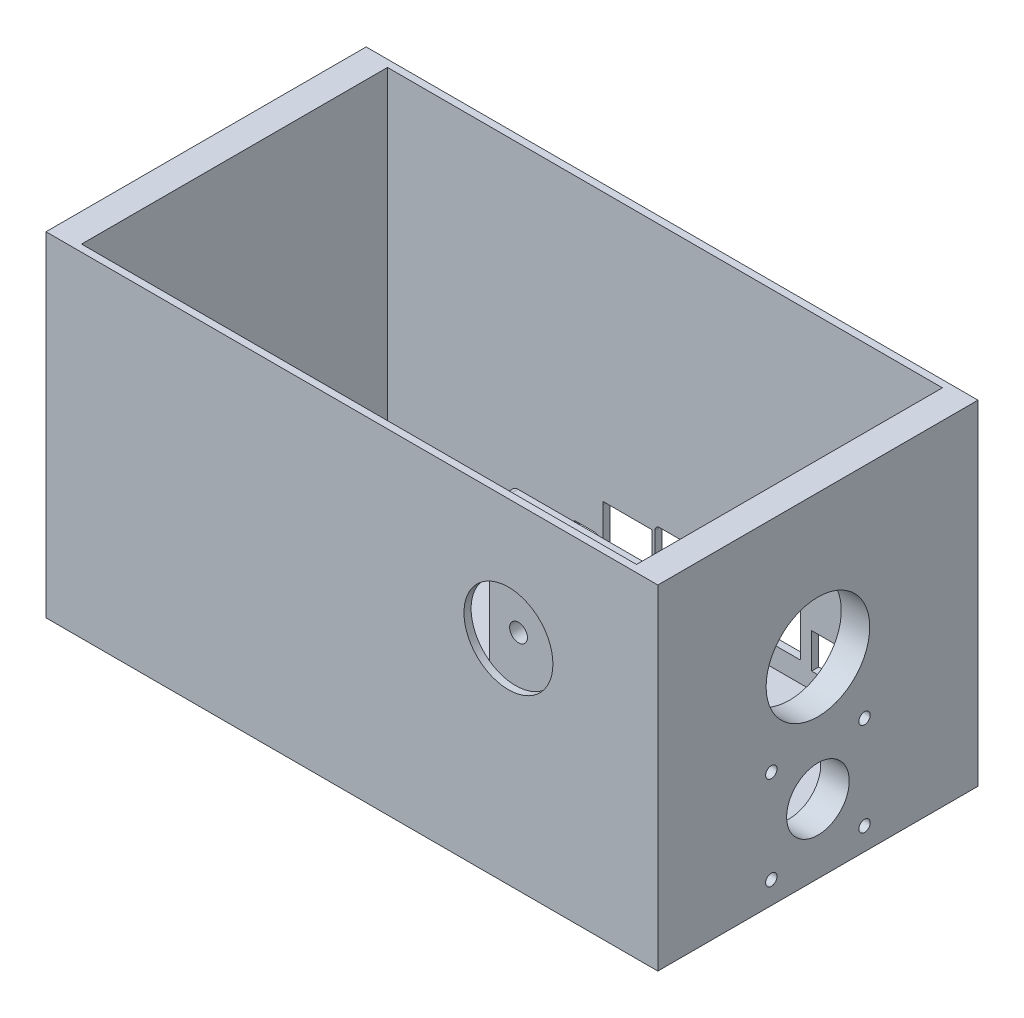
from build123d import *

# Parameters (mm, degrees)
SKETCH1_W           = 203.2
SKETCH1_H           = 114.3
BOSS_EXTRUDE1_DEPTH = 119.38
SHELL1_T            = -2.54
SKETCH2_R           = 18.5
SKETCH2_R_2         = 2.032
SKETCH2_R_3         = 11.176
CUT_EXTRUDE1_DEPTH  = 2.54
SKETCH3_W           = 114.3
SKETCH3_H           = 119.38
SKETCH3_R           = 18.5
SKETCH3_R_2         = 2.032
SKETCH3_R_3         = 11.176
BOSS_EXTRUDE3_DEPTH = 7.62
SKETCH4_R           = 15.875
CUT_EXTRUDE2_DEPTH  = 2.54
SKETCH5_W           = 50.7
SKETCH5_H           = 7.62
BOSS_EXTRUDE4_DEPTH = 95.25
CUT_EXTRUDE3_REACH  = 189.987
SKETCH6_R           = 3.175
FILLET1_R           = 2.54
FILLET2_R           = 2.54
SKETCH7_W           = 114.3
SKETCH7_H           = 119.38
BOSS_EXTRUDE5_DEPTH = 7.62
SKETCH8_R           = 2.54
SKETCH8_R_2         = 1.27
BOSS_EXTRUDE6_DEPTH = 5.08
SKETCH9_W           = 10.532
SKETCH9_H           = 12.532
CUT_EXTRUDE5_DEPTH  = 2.54


with BuildPart() as part:
    # Sketch1 → Boss-Extrude1 (new body)
    with BuildSketch(Plane(origin=(0, 0, 0), x_dir=(1, 0, 0), z_dir=(0, 1, 0))):
        Rectangle(SKETCH1_W, SKETCH1_H)
    extrude(amount=BOSS_EXTRUDE1_DEPTH)

    # Shell1
    shell1_openings = [part.faces().sort_by_distance(p)[0] for p in [
        (0, 119.38, 0),
    ]]
    offset(amount=SHELL1_T, openings=shell1_openings, kind=Kind.INTERSECTION)

    # Sketch2 → Cut-Extrude1 (cut)
    with BuildSketch(Plane.ZY.offset(-99.06)):
        with Locations((0, 68.58)):
            Circle(SKETCH2_R)
        with Locations((16.637, 41.275)):
            Circle(SKETCH2_R_2)
        with Locations(Location((16.637, 8.001, 0), (0, 0, 180))):
            Circle(SKETCH2_R_2)
        with Locations((-16.637, 8.001)):
            Circle(SKETCH2_R_2)
        with Locations(Location((-16.637, 41.275, 0), (0, 0, 180))):
            Circle(SKETCH2_R_2)
        with Locations((0, 24.638)):
            Circle(SKETCH2_R_3)
    extrude(amount=-CUT_EXTRUDE1_DEPTH, mode=Mode.SUBTRACT)

    # Sketch3 → Boss-Extrude3 (add)
    with BuildSketch(Plane(origin=(101.6, 0, 0), x_dir=(0, 0, -1), z_dir=(1, 0, 0))):
        with Locations((0, 59.69)):
            Rectangle(SKETCH3_W, SKETCH3_H)
        with Locations(Location((0, 68.58, 0), (0, 0, 180))):
            Circle(SKETCH3_R, mode=Mode.SUBTRACT)
        with Locations((-16.637, 8.001)):
            Circle(SKETCH3_R_2, mode=Mode.SUBTRACT)
        with Locations(Location((16.637, 8.001, 0), (0, 0, 180))):
            Circle(SKETCH3_R_2, mode=Mode.SUBTRACT)
        with Locations((16.637, 41.275)):
            Circle(SKETCH3_R_2, mode=Mode.SUBTRACT)
        with Locations(Location((-16.637, 41.275, 0), (0, 0, 180))):
            Circle(SKETCH3_R_2, mode=Mode.SUBTRACT)
        with Locations(Location((0, 24.638, 0), (0, 0, 180))):
            Circle(SKETCH3_R_3, mode=Mode.SUBTRACT)
    extrude(amount=BOSS_EXTRUDE3_DEPTH)

    # Sketch4 → Cut-Extrude2 (cut)
    with BuildSketch(Plane.XY.offset(57.15)):
        with Locations((55.88, 76.2)):
            Circle(SKETCH4_R)
    extrude(amount=-CUT_EXTRUDE2_DEPTH, mode=Mode.SUBTRACT)

    # Sketch5 → Boss-Extrude4 (add)
    with BuildSketch(Plane(origin=(0, 2.54, 0), x_dir=(1, 0, 0), z_dir=(0, 1, 0))):
        with Locations((55.88, -34.74)):
            Rectangle(SKETCH5_W, SKETCH5_H)
    extrude(amount=BOSS_EXTRUDE4_DEPTH)

    # Sketch6 → Cut-Extrude3 (cut, up to next)
    with BuildSketch(Plane.XY.offset(38.55), mode=Mode.PRIVATE) as cut_extrude3_sk1:
        with Locations((40.88, 91.2)):
            Circle(SKETCH6_R)
    cut_extrude3_tool1 = extrude(cut_extrude3_sk1.sketch, amount=-CUT_EXTRUDE3_REACH, mode=Mode.PRIVATE) & part.part
    # Sketch6 → Cut-Extrude3 (cut, up to next)
    with BuildSketch(Plane.XY.offset(38.55), mode=Mode.PRIVATE) as cut_extrude3_sk2:
        with Locations((70.88, 61.2)):
            Circle(SKETCH6_R)
    cut_extrude3_tool2 = extrude(cut_extrude3_sk2.sketch, amount=-CUT_EXTRUDE3_REACH, mode=Mode.PRIVATE) & part.part
    # Sketch6 → Cut-Extrude3 (cut, up to next)
    with BuildSketch(Plane.XY.offset(38.55), mode=Mode.PRIVATE) as cut_extrude3_sk3:
        with Locations((40.88, 61.2)):
            Circle(SKETCH6_R)
    cut_extrude3_tool3 = extrude(cut_extrude3_sk3.sketch, amount=-CUT_EXTRUDE3_REACH, mode=Mode.PRIVATE) & part.part
    # Sketch6 → Cut-Extrude3 (cut, up to next)
    with BuildSketch(Plane.XY.offset(38.55), mode=Mode.PRIVATE) as cut_extrude3_sk4:
        with Locations((70.88, 91.2)):
            Circle(SKETCH6_R)
    cut_extrude3_tool4 = extrude(cut_extrude3_sk4.sketch, amount=-CUT_EXTRUDE3_REACH, mode=Mode.PRIVATE) & part.part
    add(cut_extrude3_tool1.solids().sort_by_distance((40.88, 91.2, 38.55))[0], mode=Mode.SUBTRACT)
    add(cut_extrude3_tool2.solids().sort_by_distance((70.88, 61.2, 38.55))[0], mode=Mode.SUBTRACT)
    add(cut_extrude3_tool3.solids().sort_by_distance((40.88, 61.2, 38.55))[0], mode=Mode.SUBTRACT)
    add(cut_extrude3_tool4.solids().sort_by_distance((70.88, 91.2, 38.55))[0], mode=Mode.SUBTRACT)

    # Fillet1
    fillet1_edges = [part.edges().sort_by_distance(p)[0] for p in [
        (30.53, 97.79, 34.74),
        (81.23, 97.79, 34.74),
    ]]
    fillet(fillet1_edges, radius=FILLET1_R)

    # Fillet2
    fillet2_edges = [part.edges().sort_by_distance(p)[0] for p in [
        (30.53, 2.54, 34.74),
        (55.88, 2.54, 38.55),
        (81.23, 2.54, 34.74),
        (55.88, 2.54, 30.93),
    ]]
    fillet(fillet2_edges, radius=FILLET2_R)

    # Sketch7 → Boss-Extrude5 (add)
    with BuildSketch(Plane.ZY.offset(101.6)):
        with Locations((0, 59.69)):
            Rectangle(SKETCH7_W, SKETCH7_H)
    extrude(amount=BOSS_EXTRUDE5_DEPTH)

    # Sketch8 → Boss-Extrude6 (add)
    with BuildSketch(Plane(origin=(0, 2.54, 0), x_dir=(1, 0, 0), z_dir=(0, 1, 0))):
        with Locations(Location((57.72714395, -23.731482064, 0), (0, 0, 90))):
            Circle(SKETCH8_R)
        with Locations(Location((57.72714395, -23.731482064, 0), (0, 0, 270))):
            Circle(SKETCH8_R_2, mode=Mode.SUBTRACT)
        with Locations(Location((59.61714395, 34.233185903, 0), (0, 0, 90))):
            Circle(SKETCH8_R)
        with Locations(Location((59.61714395, 34.233185903, 0), (0, 0, 270))):
            Circle(SKETCH8_R_2, mode=Mode.SUBTRACT)
        with Locations(Location((-26.27785605, 34.233185903, 0), (0, 0, 90))):
            Circle(SKETCH8_R)
        with Locations(Location((-26.27785605, 34.233185903, 0), (0, 0, 270))):
            Circle(SKETCH8_R_2, mode=Mode.SUBTRACT)
        with Locations(Location((-28.27285605, -23.731482064, 0), (0, 0, 90))):
            Circle(SKETCH8_R)
        with Locations(Location((-28.27285605, -23.731482064, 0), (0, 0, 270))):
            Circle(SKETCH8_R_2, mode=Mode.SUBTRACT)
    extrude(amount=BOSS_EXTRUDE6_DEPTH)

    # Sketch9 → Cut-Extrude5 (cut)
    with BuildSketch(Plane(origin=(0, 0, -57.15), x_dir=(-1, 0, 0), z_dir=(0, 0, -1))):
        with Locations((-57.61714395, 14.695)):
            Rectangle(SKETCH9_W, SKETCH9_H)
        with BuildLine():
            Line((24.081592809, 9.382068871), (24.743724913, 8.719936793))
            ThreePointArc((24.743724913, 8.719936793), (25.203108007, 8.412986741), (25.744987314, 8.305200015))
            Line((25.744987314, 8.305200015), (28.362856093, 8.30520005))
            Line((28.362856093, 8.30520005), (28.402856063, 8.305200055))
            Line((28.402856063, 8.305200055), (31.020725099, 8.305200038))
            ThreePointArc((31.020725099, 8.305200038), (31.56260424, 8.412986824), (32.021987195, 8.719936816))
            Line((32.021987195, 8.719936816), (32.684119236, 9.382068816))
            ThreePointArc((32.684119236, 9.382068816), (32.991069464, 9.841452284), (33.09885605, 10.383332036))
            Line((33.09885605, 10.383332036), (33.09885605, 11.271200015))
            ThreePointArc((33.09885605, 11.271200015), (32.684119246, 12.272463208), (31.682856049, 12.687199998))
            Line((31.682856049, 12.687199998), (25.08285605, 12.687199999))
            ThreePointArc((25.08285605, 12.687199999), (24.08159283, 12.272463183), (23.66685605, 11.271199947))
            Line((23.66685605, 11.271199947), (23.66685605, 10.383332034))
            ThreePointArc((23.66685605, 10.383332034), (23.774642622, 9.841452319), (24.081592809, 9.382068871))
        make_face()
        Polygon((4.566873979, 8.528999922), (6.332856128, 8.529000057), (10.70285605, 8.529016793), (15.76285605, 8.529016793), (20.33285233, 8.529000057), (22.098848079, 8.528999922), (22.098856052, 22.594999424), (22.098856016, 23.660989296), (4.566853702, 23.660980854), (4.566856166, 22.594997652), align=None)
        with BuildLine():
            Line((-9.967143949, 25.681), (1.932856049, 25.681))
            ThreePointArc((1.932856049, 25.681), (3.07554061, 25.207684557), (3.54885605, 24.064999996))
            Line((3.54885605, 24.064999996), (3.54885605, 11.045))
            ThreePointArc((3.54885605, 11.045), (3.07554061, 9.902315442), (1.932856053, 9.429))
            Line((1.932856053, 9.429), (-9.96714395, 9.429))
            ThreePointArc((-9.96714395, 9.429), (-11.109828508, 9.902315442), (-11.58314395, 11.045000001))
            Line((-11.58314395, 11.045000001), (-11.58314395, 24.065))
            ThreePointArc((-11.58314395, 24.065), (-11.109828508, 25.207684559), (-9.967143949, 25.681))
        make_face()
        with BuildLine():
            Line((-26.967143949, 25.681), (-15.067143954, 25.681))
            ThreePointArc((-15.067143954, 25.681), (-13.924459392, 25.207684559), (-13.45114395, 24.064999998))
            Line((-13.45114395, 24.064999998), (-13.45114395, 11.044999999))
            ThreePointArc((-13.45114395, 11.044999999), (-13.924459391, 9.902315442), (-15.067143949, 9.429))
            Line((-15.067143949, 9.429), (-26.967143951, 9.429))
            ThreePointArc((-26.967143951, 9.429), (-28.109828509, 9.902315442), (-28.58314395, 11.045))
            Line((-28.58314395, 11.045), (-28.58314395, 24.065))
            ThreePointArc((-28.58314395, 24.065), (-28.109828508, 25.207684559), (-26.967143949, 25.681))
        make_face()
        with BuildLine():
            Line((-32.21714395, 27.3712), (-47.51714395, 27.3712))
            ThreePointArc((-47.51714395, 27.3712), (-48.082829375, 27.136885425), (-48.31714395, 26.5712))
            Line((-48.31714395, 26.5712), (-48.31714395, 10.168080492))
            ThreePointArc((-48.31714395, 10.168080492), (-48.229275984, 9.955948458), (-48.01714395, 9.868080492))
            Line((-48.01714395, 9.868080492), (-31.71714395, 9.868080492))
            ThreePointArc((-31.71714395, 9.868080492), (-31.527817248, 9.935367364), (-31.423418556, 10.107044492))
            Line((-31.423418556, 10.107044492), (-31.423418556, 26.6712))
            ThreePointArc((-31.423418556, 26.6712), (-31.687993687, 27.1712), (-32.21714395, 27.3712))
        make_face()
    extrude(amount=-CUT_EXTRUDE5_DEPTH, mode=Mode.SUBTRACT)


solid = part.part
